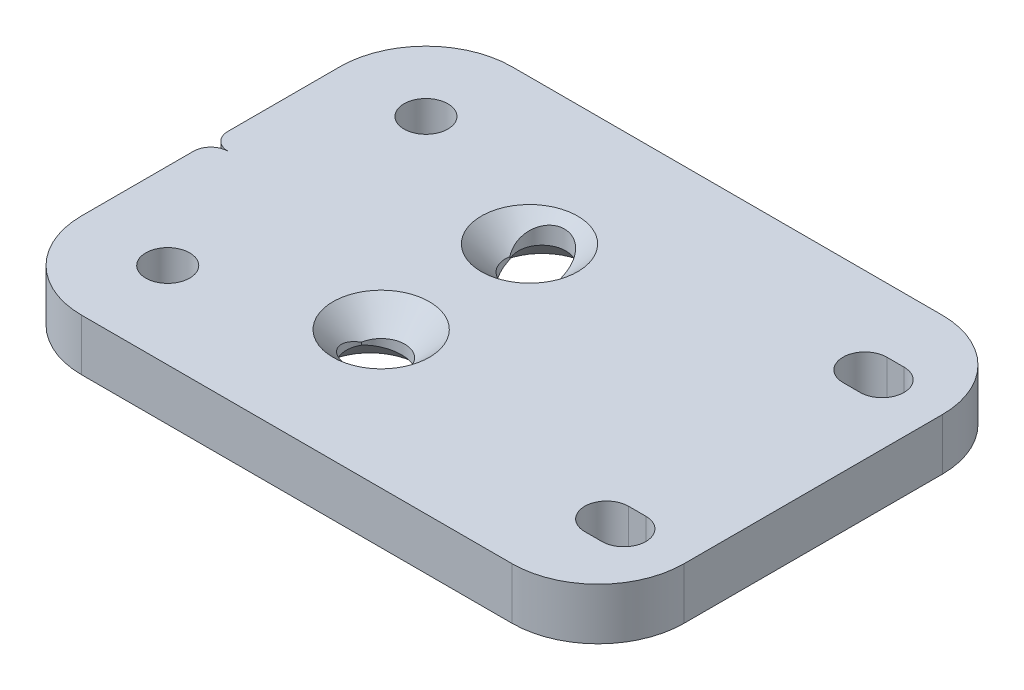
from build123d import *

# Parameters (mm, degrees)
EXTRUDE_1_DEPTH             = 6
SKETCH_2_R                  = 2.55
CUT_EXTRUDE_1_DEPTH         = 7
CUT_EXTRUDE_2_DEPTH         = 7
HOLE_WIZARD_M52_D           = 5.5
HOLE_WIZARD_M52_CSINK_D     = 11.2
HOLE_WIZARD_M52_CSINK_ANGLE = 90
HOLE_WIZARD_M51_D           = 5.5
HOLE_WIZARD_M51_CSINK_D     = 11.2
HOLE_WIZARD_M51_CSINK_ANGLE = 90


with BuildPart() as part:
    # Эскиз1 → Бобышка-Вытянуть1 (new body)
    with BuildSketch(Plane(origin=(0, 0, 0), x_dir=(1, 0, 0), z_dir=(0, 1, 0))):
        with BuildLine():
            Line((-25, -25), (25, -25))
            ThreePointArc((25, -25), (32.071067812, -22.071067812), (35, -15))
            Line((35, -15), (35, 15))
            ThreePointArc((35, 15), (32.071067812, 22.071067812), (25, 25))
            Line((25, 25), (-25, 25))
            ThreePointArc((-25, 25), (-32.071067812, 22.071067812), (-35, 15))
            Line((-35, 15), (-35, -15))
            ThreePointArc((-35, -15), (-32.071067812, -22.071067812), (-25, -25))
        make_face()
    extrude(amount=EXTRUDE_1_DEPTH)

    # Эскиз2 → Вырез-Вытянуть1 (cut, through all)
    with BuildSketch(Plane.XZ):
        with Locations((-25, -15)):
            Circle(SKETCH_2_R)
        with Locations((-25, 15)):
            Circle(SKETCH_2_R)
        with BuildLine():
            Line((28, -17.55), (26, -17.55))
            ThreePointArc((26, -17.55), (23.45, -15), (26, -12.45))
            Line((26, -12.45), (28, -12.45))
            ThreePointArc((28, -12.45), (30.55, -15), (28, -17.55))
        make_face()
        with BuildLine():
            Line((28, 17.55), (26, 17.55))
            ThreePointArc((26, 17.55), (23.45, 15), (26, 12.45))
            Line((26, 12.45), (28, 12.45))
            ThreePointArc((28, 12.45), (30.55, 15), (28, 17.55))
        make_face()
    extrude(amount=-CUT_EXTRUDE_1_DEPTH, mode=Mode.SUBTRACT)

    # Эскиз3 → Вырез-Вытянуть2 (cut, through all)
    with BuildSketch(Plane.XZ):
        with BuildLine():
            Line((-35, -2), (-35, 2))
            ThreePointArc((-35, 2), (-34.414213562, 0.585786438), (-33, 0))
            ThreePointArc((-33, 0), (-34.414213562, -0.585786438), (-35, -2))
        make_face()
    extrude(amount=-CUT_EXTRUDE_2_DEPTH, mode=Mode.SUBTRACT)

    # Зенковка для  винта с потайной головкой с внутренним шестигранником M52 (through all)
    with Locations(Plane(origin=(0, 6, 0), x_dir=(1, 0, 0), z_dir=(0, 1, 0))):
        with Locations((-6.159381211, -9.040339254), (-6.159381211, 8.192585184)):
            CounterSinkHole(HOLE_WIZARD_M52_D / 2, HOLE_WIZARD_M52_CSINK_D / 2, counter_sink_angle=HOLE_WIZARD_M52_CSINK_ANGLE)

    # Зенковка для  винта с потайной головкой с внутренним шестигранником M51 (through all)
    with Locations(Plane(origin=(0, 0, 0), x_dir=(-1, 0, 0), z_dir=(0, -1, 0))):
        with Locations((6.5, -10), (6.5, 10)):
            CounterSinkHole(HOLE_WIZARD_M51_D / 2, HOLE_WIZARD_M51_CSINK_D / 2, counter_sink_angle=HOLE_WIZARD_M51_CSINK_ANGLE)


solid = part.part
